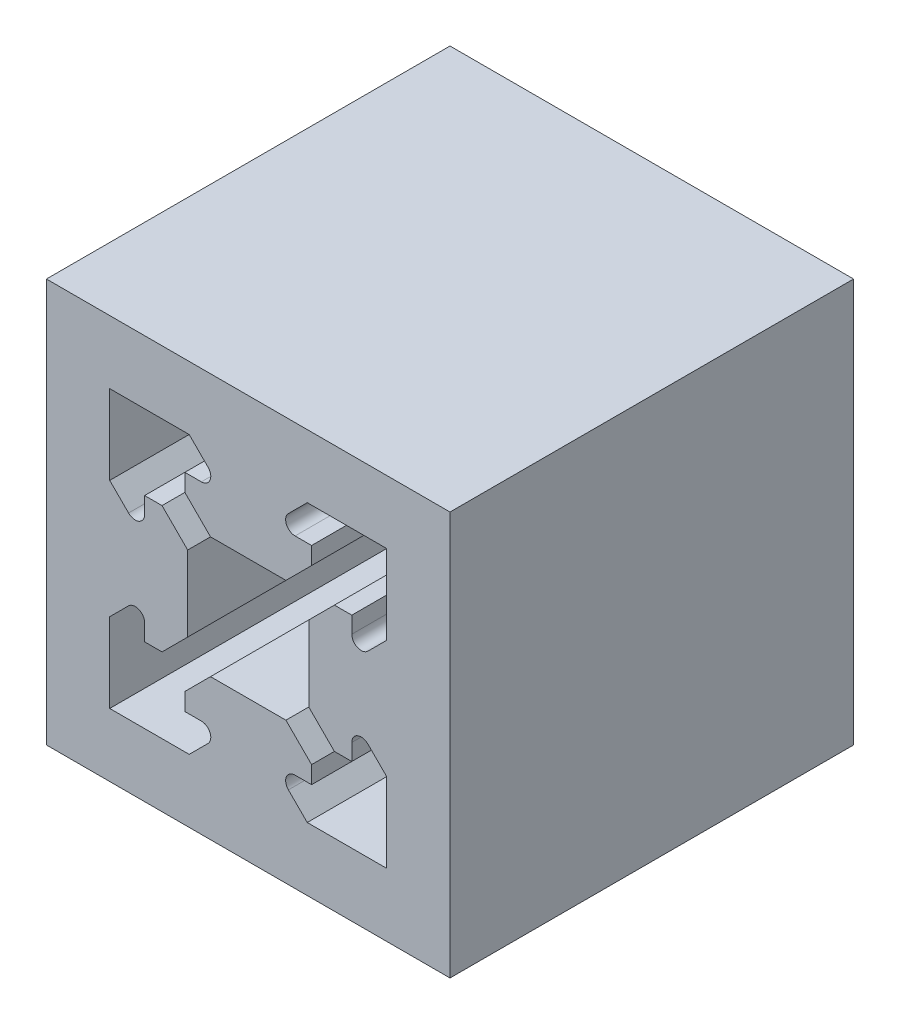
from build123d import *

# Parameters (mm, degrees)
SKETCH1_W           = 30
SKETCH1_H           = 30
BOSS_EXTRUDE1_DEPTH = 30


with BuildPart() as part:
    # Sketch1 → Boss-Extrude1 (new body)
    with BuildSketch(Plane.XY):
        with Locations((15, 15)):
            Rectangle(SKETCH1_W, SKETCH1_H)
        with BuildLine():
            Line((17.802943725, 19.5), (12.197056275, 19.5))
            Line((12.197056275, 19.5), (10.289949494, 21.407106781))
            Line((10.289949494, 21.407106781), (10.289949494, 22.7))
            Line((10.289949494, 22.7), (11.517157288, 22.7))
            ThreePointArc((11.517157288, 22.7), (12.16387296, 23.132121597), (12.012132034, 23.894974747))
            Line((12.012132034, 23.894974747), (10.612132034, 25.294974747))
            Line((10.612132034, 25.294974747), (4.705025253, 25.294974747))
            Line((4.705025253, 25.294974747), (4.705025253, 19.387867966))
            Line((4.705025253, 19.387867966), (6.105025253, 17.987867966))
            ThreePointArc((6.105025253, 17.987867966), (6.867878403, 17.83612704), (7.3, 18.482842712))
            Line((7.3, 18.482842712), (7.3, 19.710050506))
            Line((7.3, 19.710050506), (8.592893219, 19.710050506))
            Line((8.592893219, 19.710050506), (10.5, 17.802943725))
            Line((10.5, 17.802943725), (10.5, 12.197056275))
            Line((10.5, 12.197056275), (8.592893219, 10.289949494))
            Line((8.592893219, 10.289949494), (7.3, 10.289949494))
            Line((7.3, 10.289949494), (7.3, 11.517157288))
            ThreePointArc((7.3, 11.517157288), (6.867878403, 12.16387296), (6.105025253, 12.012132034))
            Line((6.105025253, 12.012132034), (4.705025253, 10.612132034))
            Line((4.705025253, 10.612132034), (4.705025253, 4.705025253))
            Line((4.705025253, 4.705025253), (10.612132034, 4.705025253))
            Line((10.612132034, 4.705025253), (12.012132034, 6.105025253))
            ThreePointArc((12.012132034, 6.105025253), (12.16387296, 6.867878403), (11.517157288, 7.3))
            Line((11.517157288, 7.3), (10.289949494, 7.3))
            Line((10.289949494, 7.3), (10.289949494, 8.592893219))
            Line((10.289949494, 8.592893219), (12.197056275, 10.5))
            Line((12.197056275, 10.5), (17.802943725, 10.5))
            Line((17.802943725, 10.5), (19.710050506, 8.592893219))
            Line((19.710050506, 8.592893219), (19.710050506, 7.3))
            Line((19.710050506, 7.3), (18.482842712, 7.3))
            ThreePointArc((18.482842712, 7.3), (17.83612704, 6.867878403), (17.987867966, 6.105025253))
            Line((17.987867966, 6.105025253), (19.387867966, 4.705025253))
            Line((19.387867966, 4.705025253), (25.294974747, 4.705025253))
            Line((25.294974747, 4.705025253), (25.294974747, 10.612132034))
            Line((25.294974747, 10.612132034), (23.894974747, 12.012132034))
            ThreePointArc((23.894974747, 12.012132034), (23.132121597, 12.16387296), (22.7, 11.517157288))
            Line((22.7, 11.517157288), (22.7, 10.289949494))
            Line((22.7, 10.289949494), (21.407106781, 10.289949494))
            Line((21.407106781, 10.289949494), (19.5, 12.197056275))
            Line((19.5, 12.197056275), (19.5, 17.802943725))
            Line((19.5, 17.802943725), (21.407106781, 19.710050506))
            Line((21.407106781, 19.710050506), (22.7, 19.710050506))
            Line((22.7, 19.710050506), (22.7, 18.482842712))
            ThreePointArc((22.7, 18.482842712), (23.132121597, 17.83612704), (23.894974747, 17.987867966))
            Line((23.894974747, 17.987867966), (25.294974747, 19.387867966))
            Line((25.294974747, 19.387867966), (25.294974747, 25.294974747))
            Line((25.294974747, 25.294974747), (19.387867966, 25.294974747))
            Line((19.387867966, 25.294974747), (17.987867966, 23.894974747))
            ThreePointArc((17.987867966, 23.894974747), (17.83612704, 23.132121597), (18.482842712, 22.7))
            Line((18.482842712, 22.7), (19.710050506, 22.7))
            Line((19.710050506, 22.7), (19.710050506, 21.407106781))
            Line((19.710050506, 21.407106781), (17.802943725, 19.5))
        make_face(mode=Mode.SUBTRACT)
    extrude(amount=BOSS_EXTRUDE1_DEPTH)


solid = part.part
